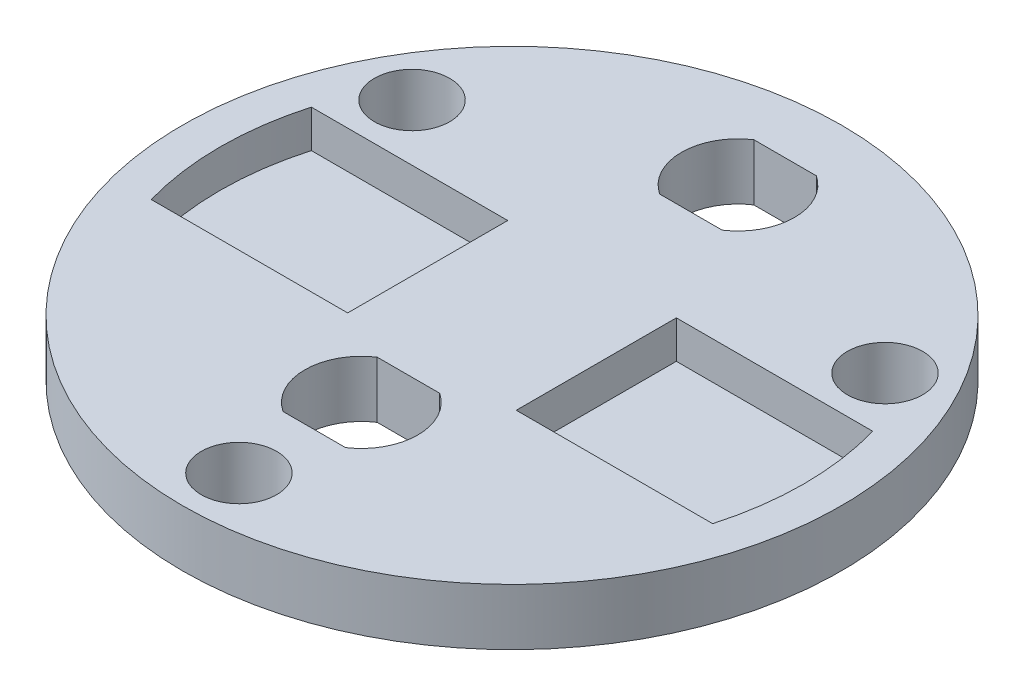
from build123d import *

# Parameters (mm, degrees)
CROQUIS1_R              = 17.5
CROQUIS1_R_2            = 13.5
SALIENTE_EXTRUIR1_DEPTH = 3
CORTAR_EXTRUIR1_DEPTH   = 2
CROQUIS3_R              = 2
CORTAR_EXTRUIR2_DEPTH   = 25.929901725
CORTAR_EXTRUIR3_DEPTH   = 10


with BuildPart() as part:
    # Croquis1 → Saliente-Extruir1 (new body)
    with BuildSketch(Plane(origin=(0, 0, 0), x_dir=(1, 0, 0), z_dir=(0, 1, 0))):
        with Locations(Location((0, 0, 0), (0, 0, 270))):
            Circle(CROQUIS1_R)
        Circle(CROQUIS1_R_2, mode=Mode.SUBTRACT)
        Circle(CROQUIS1_R_2)
    extrude(amount=SALIENTE_EXTRUIR1_DEPTH)

    # Croquis2 → Cortar-Extruir1 (cut)
    with BuildSketch(Plane(origin=(0, 3, 0), x_dir=(1, 0, 0), z_dir=(0, 1, 0))):
        with BuildLine():
            Line((-15.5, 0), (-4.476086121, 0))
            Line((-4.476086121, 0), (-4.476086121, 4.25))
            Line((-4.476086121, 4.25), (-14.905955186, 4.25))
            ThreePointArc((-14.905955186, 4.25), (-15.350770427, 2.14565778), (-15.5, 0))
        make_face()
        with BuildLine():
            Line((-4.476086121, -4.25), (-4.476086121, 0))
            Line((-4.476086121, 0), (-15.5, 0))
            ThreePointArc((-15.5, 0), (-15.350770427, -2.14565778), (-14.905955186, -4.25))
            Line((-14.905955186, -4.25), (-4.476086121, -4.25))
        make_face()
        with BuildLine():
            ThreePointArc((15.5, 0), (15.350770427, 2.14565778), (14.905955186, 4.25))
            Line((14.905955186, 4.25), (4.476086121, 4.25))
            Line((4.476086121, 4.25), (4.476086121, -4.25))
            Line((4.476086121, -4.25), (14.905955186, -4.25))
            ThreePointArc((14.905955186, -4.25), (15.350770427, -2.14565778), (15.5, 0))
        make_face()
    extrude(amount=-CORTAR_EXTRUIR1_DEPTH, mode=Mode.SUBTRACT)

    # Croquis3 → Cortar-Extruir2 (cut, through all)
    with BuildSketch(Plane(origin=(0, 0, 0), x_dir=(-1, 0, 0), z_dir=(0, -1, 0))):
        with Locations(Location((0, -14.5, 0), (0, 0, 90))):
            Circle(CROQUIS3_R)
        with Locations(Location((12.557368355, 7.25, 0), (0, 0, 90))):
            Circle(CROQUIS3_R)
        with Locations(Location((-12.557368355, 7.25, 0), (0, 0, 90))):
            Circle(CROQUIS3_R)
    extrude(amount=-CORTAR_EXTRUIR2_DEPTH, mode=Mode.SUBTRACT)

    # Croquis4 → Cortar-Extruir3 (cut)
    with BuildSketch(Plane(origin=(0, 0, 0), x_dir=(-1, 0, 0), z_dir=(0, -1, 0))):
        with BuildLine():
            Line((1.658312395, 14.5), (-1.658312395, 14.5))
            ThreePointArc((-1.658312395, 14.5), (-3, 12), (-1.658312395, 9.5))
            Line((-1.658312395, 9.5), (1.658312395, 9.5))
            ThreePointArc((1.658312395, 9.5), (3, 12), (1.658312395, 14.5))
        make_face()
        with BuildLine():
            Line((1.658312395, -5.5), (-1.658312395, -5.5))
            ThreePointArc((-1.658312395, -5.5), (-3, -8), (-1.658312395, -10.5))
            Line((-1.658312395, -10.5), (1.658312395, -10.5))
            ThreePointArc((1.658312395, -10.5), (3, -8), (1.658312395, -5.5))
        make_face()
    extrude(amount=-CORTAR_EXTRUIR3_DEPTH, mode=Mode.SUBTRACT)


solid = part.part
